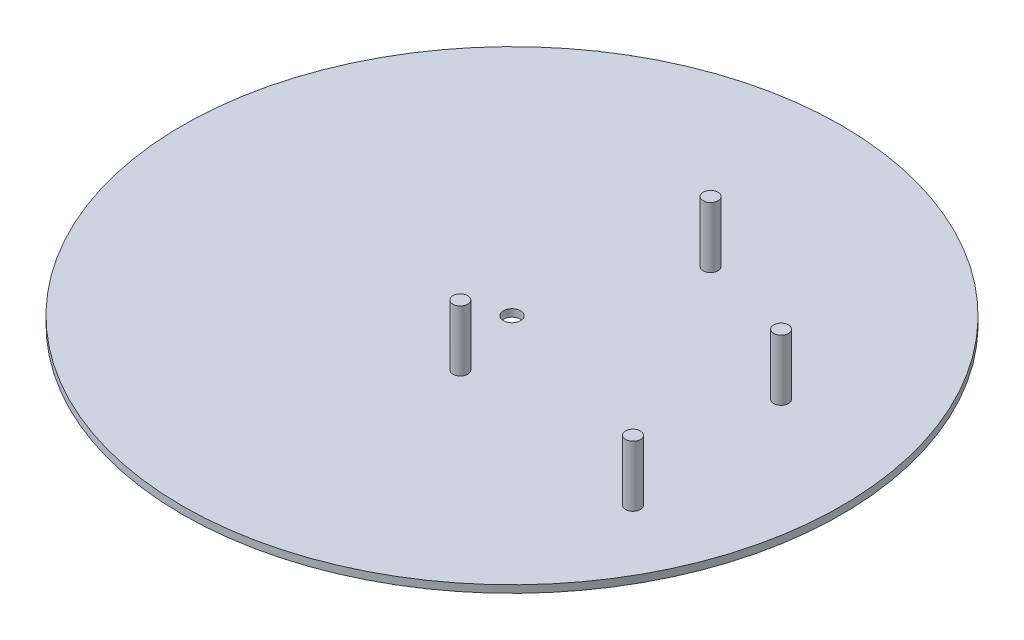
from build123d import *

# Parameters (mm, degrees)
SKETCH1_R            = 111.264222233
SKETCH1_R_2          = 2.92
SKETCH1_R_3          = 2.5
BOSS_EXTRUDE12_DEPTH = 2.5
SKETCH5_R            = 2.5
BOSS_EXTRUDE15_DEPTH = 23
SKETCH6_R            = 2.5
BOSS_EXTRUDE16_DEPTH = 23
SKETCH7_R            = 2.5
BOSS_EXTRUDE17_DEPTH = 23
SKETCH3_R            = 2.5
BOSS_EXTRUDE18_DEPTH = 23


with BuildPart() as part:
    # Sketch1 → Boss-Extrude12 (new body)
    with BuildSketch(Plane(origin=(0, 0, 0), x_dir=(1, 0, 0), z_dir=(0, 1, 0))):
        Circle(SKETCH1_R)
        Circle(SKETCH1_R_2, mode=Mode.SUBTRACT)
        with Locations((75.852459016, -35)):
            Circle(SKETCH1_R_3, mode=Mode.SUBTRACT)
        with Locations((69.852459016, 21)):
            Circle(SKETCH1_R_3, mode=Mode.SUBTRACT)
        with Locations((19.152459016, 47.9)):
            Circle(SKETCH1_R_3, mode=Mode.SUBTRACT)
        with Locations((7.152459016, -24.6)):
            Circle(SKETCH1_R_3, mode=Mode.SUBTRACT)
    extrude(amount=BOSS_EXTRUDE12_DEPTH)

    # Sketch5 → Boss-Extrude15 (add)
    with BuildSketch(Plane(origin=(0, 0, 0), x_dir=(-1, 0, 0), z_dir=(0, -1, 0))):
        with Locations((-19.152459016, 47.9)):
            Circle(SKETCH5_R)
    extrude(amount=-BOSS_EXTRUDE15_DEPTH)

    # Sketch6 → Boss-Extrude16 (add)
    with BuildSketch(Plane(origin=(0, 0, 0), x_dir=(-1, 0, 0), z_dir=(0, -1, 0))):
        with Locations((-69.852459016, 21)):
            Circle(SKETCH6_R)
    extrude(amount=-BOSS_EXTRUDE16_DEPTH)

    # Sketch7 → Boss-Extrude17 (add)
    with BuildSketch(Plane(origin=(0, 0, 0), x_dir=(-1, 0, 0), z_dir=(0, -1, 0))):
        with Locations((-75.852459016, -35)):
            Circle(SKETCH7_R)
    extrude(amount=-BOSS_EXTRUDE17_DEPTH)

    # Sketch3 → Boss-Extrude18 (add)
    with BuildSketch(Plane(origin=(0, 0, 0), x_dir=(-1, 0, 0), z_dir=(0, -1, 0))):
        with Locations((-7.152459016, -24.6)):
            Circle(SKETCH3_R)
    extrude(amount=-BOSS_EXTRUDE18_DEPTH)


solid = part.part
